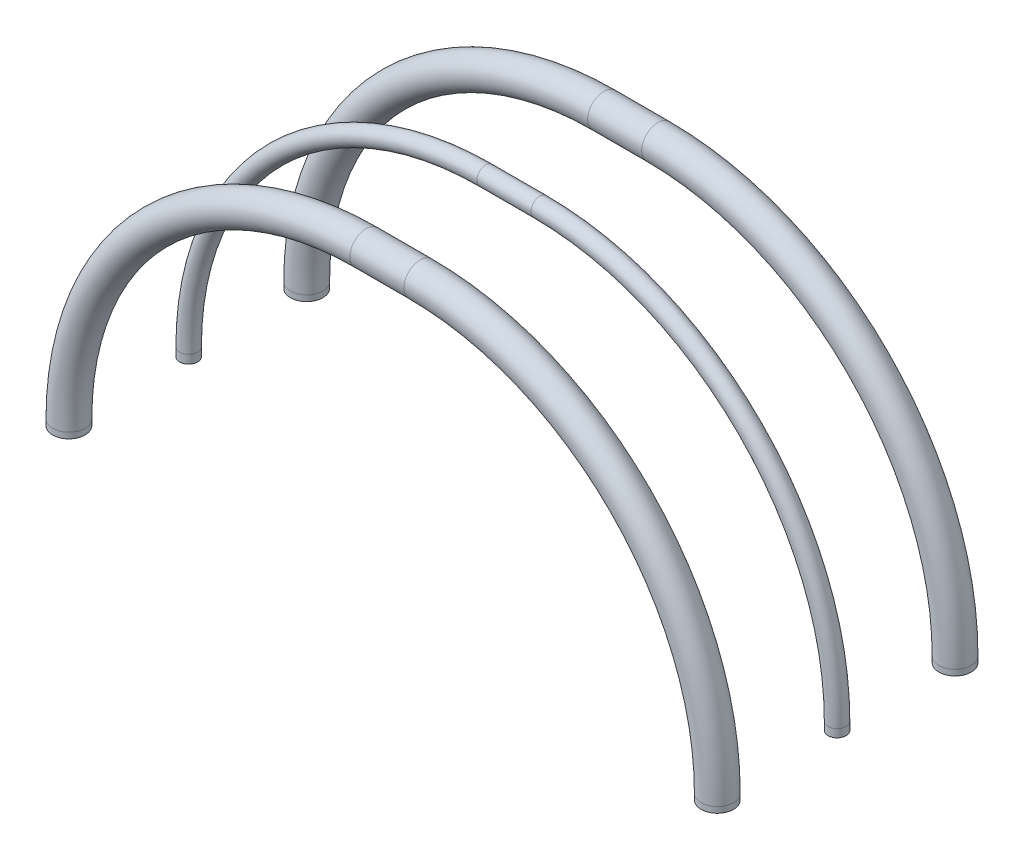
from build123d import *

# Parameters (mm, degrees)
SWEEP_THIN1_PROFILE_R   = 30
SWEEP_THIN1_PROFILE_R_2 = 29
LPATTERN1_COUNT         = 2
LPATTERN1_PITCH         = 440
SWEEP_THIN2_PROFILE_R   = 16.7
SWEEP_THIN2_PROFILE_R_2 = 15.7


with BuildPart() as part:
    # Sweep-Thin1: sweep along a curve in space
    with BuildLine() as sweep_thin1_path:
        Line((-21650.481156353, 11703.450620788, 40762.495847847), (-21650.481156353, 11714.22348202, 40762.495847847))
        ThreePointArc((-21650.481156353, 11714.22348202, 40762.495847847), (-21811.5724267, 12103.132211673, 40762.495847847), (-22200.481156353, 12264.22348202, 40762.495847847))
        Line((-22200.481156353, 12264.22348202, 40762.495847847), (-22300.481156353, 12264.22348202, 40762.495847847))
        ThreePointArc((-22850.481156353, 11714.22348202, 40762.495847847), (-22689.389886006, 12103.132211673, 40762.495847847), (-22300.481156353, 12264.22348202, 40762.495847847))
        Line((-22850.481156353, 11703.450620788, 40762.495847847), (-22850.481156353, 11714.22348202, 40762.495847847))
    # Sweep-Thin1 profile (on start of the path) → Sweep-Thin1 (sweep)
    with BuildSketch(Plane(origin=(-21650.481156353, 11703.450620788, 40762.495847847), x_dir=(0, 0, 1), z_dir=(0, 1, 0))):
        Circle(SWEEP_THIN1_PROFILE_R)
        Circle(SWEEP_THIN1_PROFILE_R_2, mode=Mode.SUBTRACT)
    sweep(path=sweep_thin1_path.line)


with BuildPart() as lpattern1_1:
    # LPattern1: pattern copy
    add(part.part.moved(Location(Vector(0, 0, -1) * (1 * LPATTERN1_PITCH))))


with BuildPart() as body_3:
    # Sweep-Thin2: sweep along a curve in space
    with BuildLine() as sweep_thin2_path:
        Line((-21649.981340534, 11704.606319434, 40541.378498075), (-21649.981340534, 11719.39418129, 40541.378498075))
        ThreePointArc((-22199.981340534, 12269.39418129, 40541.378498075), (-21811.072610882, 12108.302910942, 40541.378498075), (-21649.981340534, 11719.39418129, 40541.378498075))
        Line((-22199.981340534, 12269.39418129, 40541.378498075), (-22299.981340534, 12269.39418129, 40541.378498075))
        ThreePointArc((-22299.981340534, 12269.39418129, 40541.378498075), (-22688.890070187, 12108.302910942, 40541.378498075), (-22849.981340534, 11719.39418129, 40541.378498075))
        Line((-22849.981340534, 11719.39418129, 40541.378498075), (-22849.981340534, 11703.548789379, 40541.378498075))
    # Sweep-Thin2 profile (on start of the path) → Sweep-Thin2 (sweep)
    with BuildSketch(Plane(origin=(-21649.981340534, 11704.606319434, 40541.378498075), x_dir=(0, 0, 1), z_dir=(0, 1, 0))):
        Circle(SWEEP_THIN2_PROFILE_R)
        Circle(SWEEP_THIN2_PROFILE_R_2, mode=Mode.SUBTRACT)
    sweep(path=sweep_thin2_path.line)


solid = Compound([part.part, lpattern1_1.part, body_3.part])
